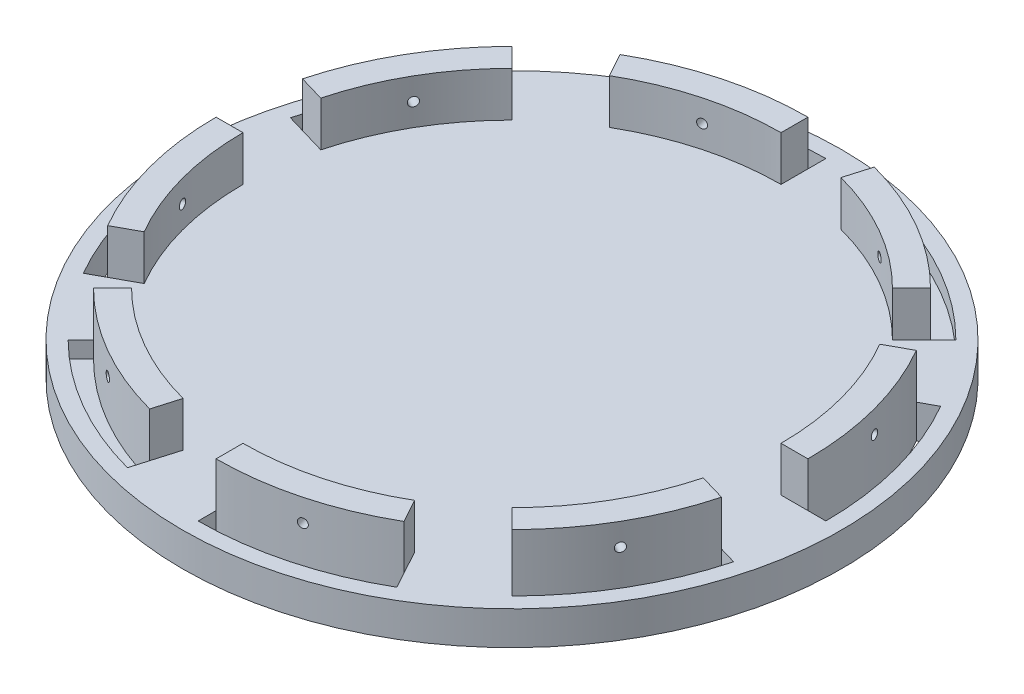
from build123d import *

# Parameters (mm, degrees)
BASE_DEPTH                 = 4.7625
BASE_DEPTH_BACK            = 4.7625
SKETCH1_R                  = 93.345
BOTTOM_SUPPORT_HOLES_DEPTH = 133.352951138
BOTTOM_START               = 12.7
BOTTOM_SUPPORT_GUIDE_DEPTH = 12.7
SKETCH6_R                  = 1.27
BOTTOM_BOLT_HOLE_DEPTH     = 12.7
TOP_SUPPORT_HOLES_DEPTH    = 4.7625
TOP_START                  = 12.7
TOP_SUPPORT_GUIDE_DEPTH    = 12.7
SKETCH12_R                 = 1.27
TOP_BOLT_HOLE_DEPTH        = 12.7
BOTTOM_PATTERN_COUNT       = 4
CIRPATTERN3_COUNT          = 4


with BuildPart() as part:
    # Sketch1 → Base (new, two sides: drawn at the far end of the back side and taken through both)
    with BuildSketch(Plane(origin=(0, 0, 0), x_dir=(1, 0, 0), z_dir=(0, 1, 0)).offset(-BASE_DEPTH_BACK)):
        Circle(SKETCH1_R)
    extrude(amount=BASE_DEPTH + BASE_DEPTH_BACK)

    # Sketch2 → Bottom support holes (cut, through all)
    with BuildSketch(Plane(origin=(0, 4.7625, 0), x_dir=(1, 0, 0), z_dir=(0, 1, 0))):
        with BuildLine():
            Line((0, 88.9), (0, 83.82))
            ThreePointArc((0, 83.82), (-21.72026739, 80.956916842), (-41.956713931, 72.563258996))
            Line((-41.956713931, 72.563258996), (-44.39288973, 77.022602796))
            ThreePointArc((-44.39288973, 77.022602796), (-22.977169228, 85.879332172), (0, 88.9))
        make_face()
    bottom_support_holes = extrude(amount=-BOTTOM_SUPPORT_HOLES_DEPTH, mode=Mode.SUBTRACT)

    # Sketch3 → Bottom support guide (add)
    with BuildSketch(Plane(origin=(0, 4.7625, 0), x_dir=(1, 0, 0), z_dir=(0, 1, 0)).offset(BOTTOM_START)):
        with BuildLine():
            Line((0, 83.82), (0, 76.2))
            ThreePointArc((0, 76.2), (-19.834896001, 73.573207764), (-38.302281481, 65.8739344))
            Line((-38.302281481, 65.8739344), (-41.956713931, 72.563258996))
            ThreePointArc((-41.956713931, 72.563258996), (-21.72026739, 80.956916842), (0, 83.82))
        make_face()
    bottom_support_guide = extrude(amount=-BOTTOM_SUPPORT_GUIDE_DEPTH)

    # Sketch6 → Bottom bolt hole (cut, symmetric)
    with BuildSketch(Plane(origin=(-20.978356966, 0, -78.191629498), x_dir=(-0.9658424820058785, 0, 0.2591298901183038), z_dir=(-0.2591298901183038, 0, -0.9658424820058785))):
        with Locations((-0.00326739, 11.1125)):
            Circle(SKETCH6_R)
    bottom_bolt_hole = extrude(amount=BOTTOM_BOLT_HOLE_DEPTH, both=True, mode=Mode.SUBTRACT)

    # Sketch8 → Top support holes (cut)
    with BuildSketch(Plane(origin=(-31.122978549, 4.7625, 77.296707326), x_dir=(1, 0, 0), z_dir=(0, 1, 0))):
        with BuildLine():
            Line((-31.738814298, 140.158500173), (-28.14671185, 136.566397725))
            ThreePointArc((-28.14671185, 136.566397725), (-41.480754694, 119.183343848), (-49.854870889, 98.93880289))
            Line((-49.854870889, 98.93880289), (-54.730739557, 100.369398703))
            ThreePointArc((-54.730739557, 100.369398703), (-45.850191767, 121.775253295), (-31.738814298, 140.158500173))
        make_face()
    top_support_holes = extrude(amount=-TOP_SUPPORT_HOLES_DEPTH, mode=Mode.SUBTRACT)

    # Sketch10 → Top support guide (add)
    with BuildSketch(Plane(origin=(-31.122978549, 4.7625, 77.296707326), x_dir=(1, 0, 0), z_dir=(0, 1, 0)).offset(TOP_START)):
        with BuildLine():
            Line((-28.14671185, 136.566397725), (-22.758558177, 131.178244052))
            ThreePointArc((-22.758558177, 131.178244052), (-34.92652504, 115.295431983), (-42.540730139, 96.792810073))
            Line((-42.540730139, 96.792810073), (-49.854870889, 98.93880289))
            ThreePointArc((-49.854870889, 98.93880289), (-41.480754694, 119.183343848), (-28.14671185, 136.566397725))
        make_face()
    top_support_guide = extrude(amount=-TOP_SUPPORT_GUIDE_DEPTH)

    # Sketch12 → Top bolt hole (cut, symmetric)
    with BuildSketch(Plane(origin=(-70.123769919, 0, -40.455892982), x_dir=(-0.4997212660736201, -5.817861610189737e-15, 0.8661862710951832), z_dir=(-0.8661862710951832, 1.404556040332972e-14, -0.4997212660736201))):
        with Locations((-0.00326739, 11.1125)):
            Circle(SKETCH12_R)
    top_bolt_hole = extrude(amount=TOP_BOLT_HOLE_DEPTH, both=True, mode=Mode.SUBTRACT)

    # Bottom pattern: Bottom support holes, Bottom support guide, Bottom bolt hole ×4 about axis
    bottom_pattern_axis = Axis((0, 4.7625, 0), (0, 1, 0))
    add([bottom_support_holes.rotate(bottom_pattern_axis, i * 360 / BOTTOM_PATTERN_COUNT) for i in range(1, BOTTOM_PATTERN_COUNT)], mode=Mode.SUBTRACT)
    add([bottom_support_guide.rotate(bottom_pattern_axis, i * 360 / BOTTOM_PATTERN_COUNT) for i in range(1, BOTTOM_PATTERN_COUNT)])
    add([bottom_bolt_hole.rotate(bottom_pattern_axis, i * 360 / BOTTOM_PATTERN_COUNT) for i in range(1, BOTTOM_PATTERN_COUNT)], mode=Mode.SUBTRACT)

    # CirPattern3: Top support holes, Top support guide, Top bolt hole ×4 about axis
    cirpattern3_axis = Axis((0, 4.7625, 0), (0, 1, 0))
    add([top_support_holes.rotate(cirpattern3_axis, i * 360 / CIRPATTERN3_COUNT) for i in range(1, CIRPATTERN3_COUNT)], mode=Mode.SUBTRACT)
    add([top_support_guide.rotate(cirpattern3_axis, i * 360 / CIRPATTERN3_COUNT) for i in range(1, CIRPATTERN3_COUNT)])
    add([top_bolt_hole.rotate(cirpattern3_axis, i * 360 / CIRPATTERN3_COUNT) for i in range(1, CIRPATTERN3_COUNT)], mode=Mode.SUBTRACT)


solid = part.part
